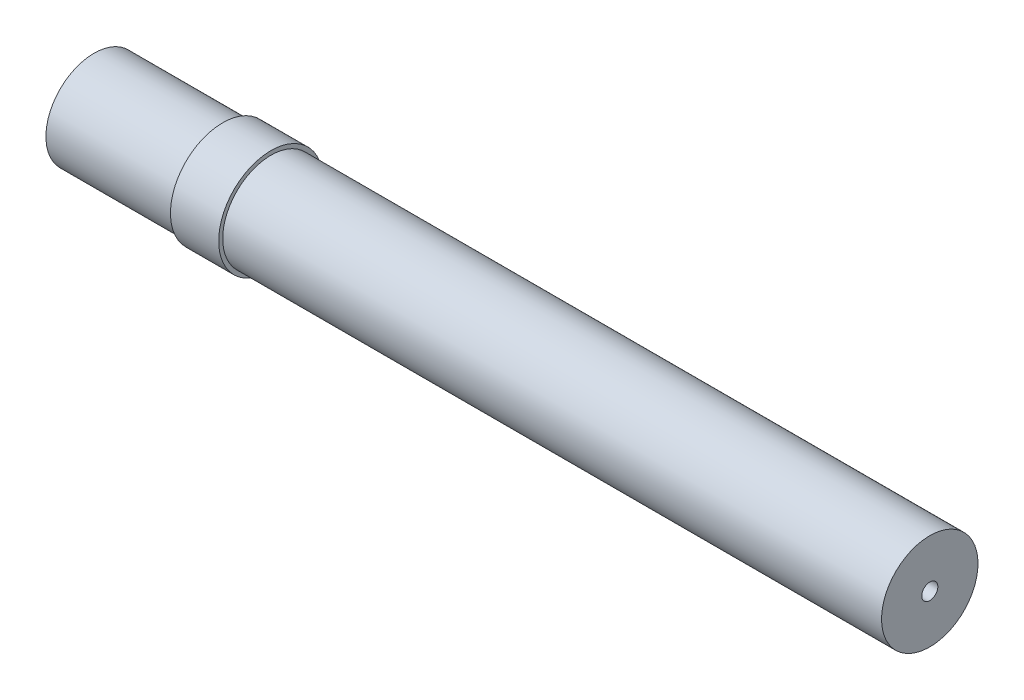
from build123d import *


with BuildPart() as part:
    # Sketch1 → Revolve1 (revolve)
    with BuildSketch(Plane.XY):
        Polygon((10, 0.5), (11, 0.5), (11, 3), (-30, 3), (-30, 3.25), (-33, 3.25), (-33, 3), (-41, 3), (-41, 2.25), (10, 2.25), align=None)
    revolve(axis=Axis((13.5, 0, 0), (-1, 0, 0)))


solid = part.part
